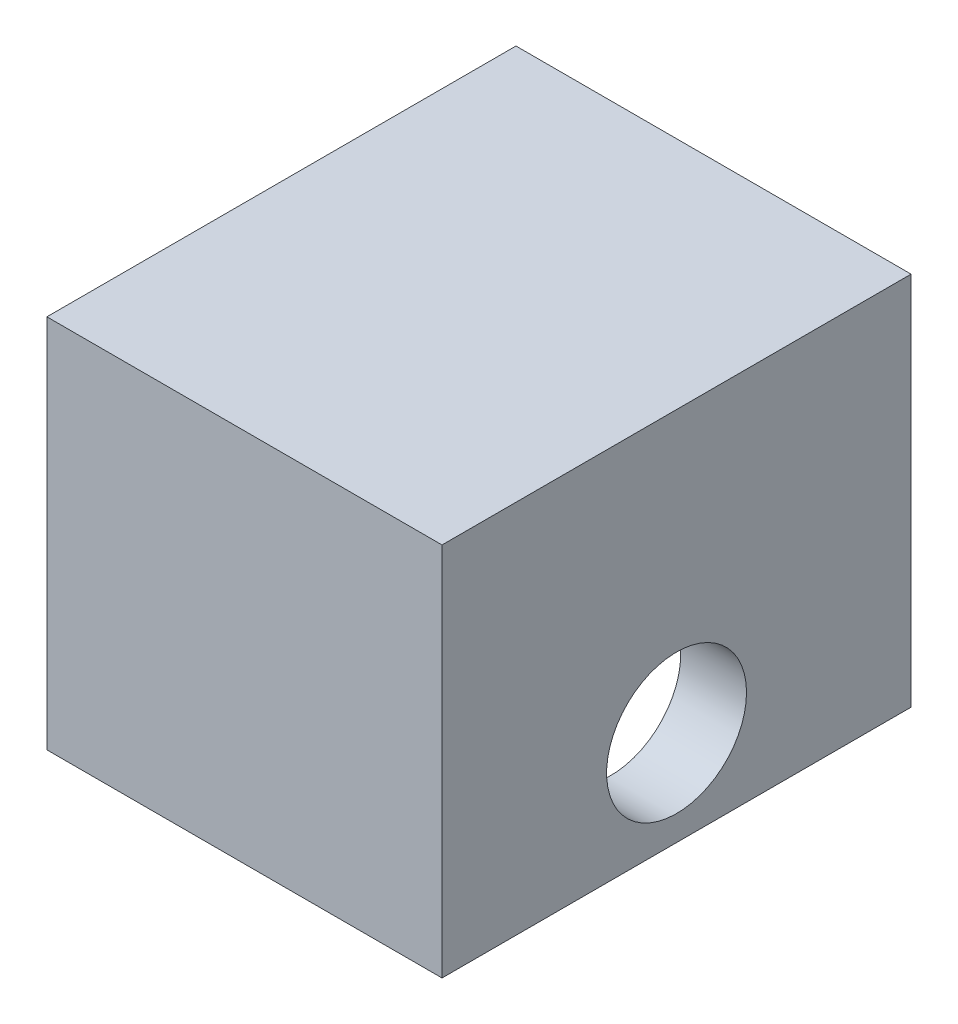
from build123d import *

# Parameters (mm, degrees)
BOSS_EXTRUDE1_DEPTH = 10.24636
SKETCH2_R           = 2.12471
CUT_EXTRUDE1_DEPTH  = 12.99896
SKETCH3_W           = 10.24636
SKETCH3_H           = 0.6985
CUT_EXTRUDE2_DEPTH  = 12.99896
SKETCH4_W           = 1.99898
SKETCH4_H           = 11.38936
BOSS_EXTRUDE2_DEPTH = 11.99896


with BuildPart() as part:
    # Sketch1 → Boss-Extrude1 (new body)
    with BuildSketch(Plane.XY):
        Polygon((0, 0), (0, 10.08888), (8.001, 10.08888), (8.001, 0), (9.99998, 0), (9.99998, 12.08786), (-1.99898, 12.08786), (-1.99898, 0), align=None)
    extrude(amount=BOSS_EXTRUDE1_DEPTH)

    # Sketch2 → Cut-Extrude1 (cut, through all)
    with BuildSketch(Plane(origin=(9.99998, 0, 0), x_dir=(0, 0, -1), z_dir=(1, 0, 0))):
        with Locations((-5.12318, 3.58648)):
            Circle(SKETCH2_R)
    extrude(amount=-CUT_EXTRUDE1_DEPTH, mode=Mode.SUBTRACT)

    # Sketch3 → Cut-Extrude2 (cut, through all)
    with BuildSketch(Plane(origin=(9.99998, 0, 0), x_dir=(0, 0, -1), z_dir=(1, 0, 0))):
        with Locations((-5.12318, 0.34925)):
            Rectangle(SKETCH3_W, SKETCH3_H)
    extrude(amount=-CUT_EXTRUDE2_DEPTH, mode=Mode.SUBTRACT)

    # Sketch4 → Boss-Extrude2 (add)
    with BuildSketch(Plane(origin=(9.99998, 0, 0), x_dir=(0, 0, -1), z_dir=(1, 0, 0))):
        with Locations((-11.24585, 6.39318)):
            Rectangle(SKETCH4_W, SKETCH4_H)
        with Locations((0.99949, 6.39318)):
            Rectangle(SKETCH4_W, SKETCH4_H)
    extrude(amount=-BOSS_EXTRUDE2_DEPTH)


solid = part.part
